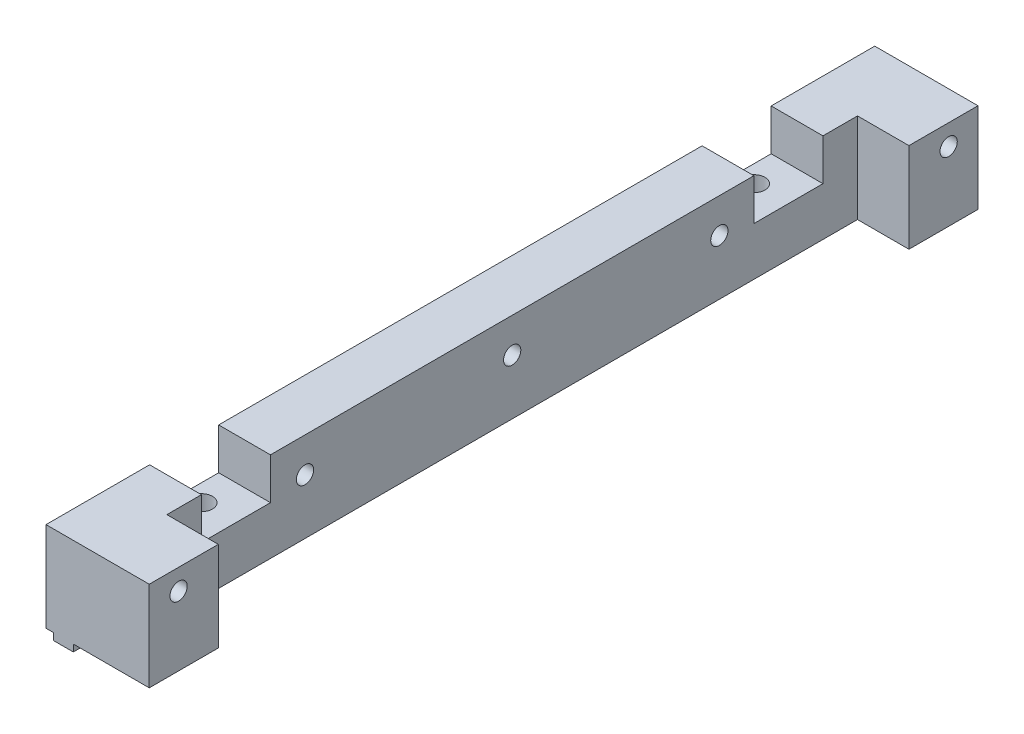
from build123d import *

# Parameters (mm, degrees)
MAIN_DEPTH               = 60
ESQUISSE2_R              = 1.25
HOLESFORMOTORBOARD_DEPTH = 15.95
ESQUISSE4_R              = 1.6
HOLESFORMAKERBEAM_DEPTH  = 15
SKETCH1_W                = 100
SKETCH1_H                = 13
POWERBOARDPINHOLES_DEPTH = 7.45
SKETCH2_R                = 1.25
WINDOWFIXHOLES_DEPTH     = 15.95
SKETCH3_W                = 10
SKETCH3_H                = 6
CUT_EXTRUDE1_DEPTH       = 15.95


with BuildPart() as part:
    # Esquisse1 → Main (new body, symmetric)
    with BuildSketch(Plane.XY):
        Polygon((0, 13), (14.95, 13), (14.95, 0), (3.95, 0), (3.95, -1), (1.05, -1), (1.05, 0), (0, 0), align=None)
    extrude(amount=MAIN_DEPTH, both=True)

    # Esquisse2 → HolesForMotorBoard (cut, through all)
    with BuildSketch(Plane(origin=(14.95, 0, 0), x_dir=(0, 0, -1), z_dir=(1, 0, 0))):
        with Locations((55.75, 10)):
            Circle(ESQUISSE2_R)
        with Locations((-55.75, 10)):
            Circle(ESQUISSE2_R)
    extrude(amount=-HOLESFORMOTORBOARD_DEPTH, mode=Mode.SUBTRACT)

    # Esquisse4 → HolesForMakerBeam (cut, through all)
    with BuildSketch(Plane(origin=(0, -1, 0), x_dir=(-1, 0, 0), z_dir=(0, -1, 0))):
        with Locations((-2.5, -40)):
            Circle(ESQUISSE4_R)
        with Locations((-2.5, 40)):
            Circle(ESQUISSE4_R)
    extrude(amount=-HOLESFORMAKERBEAM_DEPTH, mode=Mode.SUBTRACT)

    # Sketch1 → PowerBoardPinHoles (cut)
    with BuildSketch(Plane(origin=(14.95, 0, 0), x_dir=(0, 0, -1), z_dir=(1, 0, 0))):
        with Locations((0, 6.5)):
            Rectangle(SKETCH1_W, SKETCH1_H)
    extrude(amount=-POWERBOARDPINHOLES_DEPTH, mode=Mode.SUBTRACT)

    # Sketch2 → WindowFixHoles (cut, through all)
    with BuildSketch(Plane.ZY):
        with Locations((0, 8)):
            Circle(SKETCH2_R)
        with Locations((-30, 8)):
            Circle(SKETCH2_R)
        with Locations((30, 8)):
            Circle(SKETCH2_R)
    extrude(amount=-WINDOWFIXHOLES_DEPTH, mode=Mode.SUBTRACT)

    # Sketch3 → Cut-Extrude1 (cut, through all)
    with BuildSketch(Plane.ZY):
        with Locations((-40, 10)):
            Rectangle(SKETCH3_W, SKETCH3_H)
        with Locations((40, 10)):
            Rectangle(SKETCH3_W, SKETCH3_H)
    extrude(amount=-CUT_EXTRUDE1_DEPTH, mode=Mode.SUBTRACT)


solid = part.part
